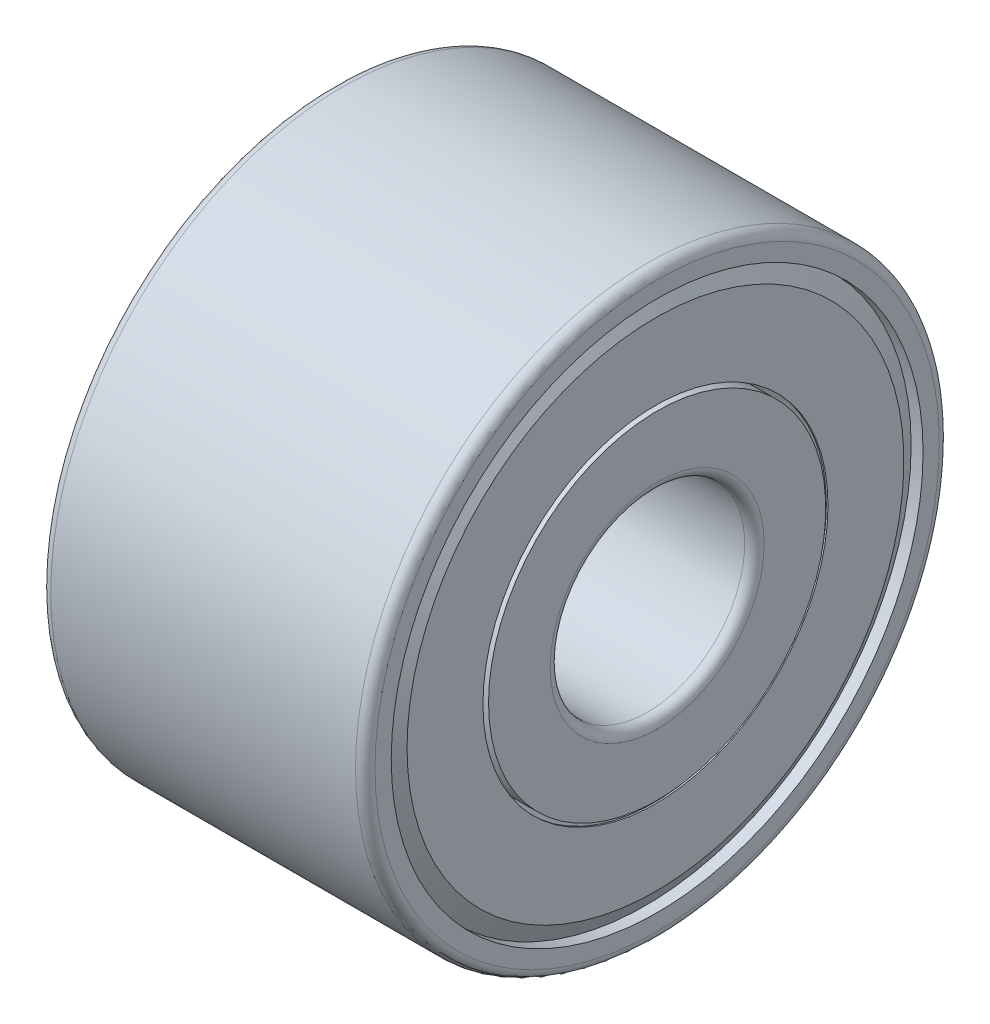
from build123d import *


with BuildPart() as part:
    # Esquisse1 → Révolution1 (revolve)
    with BuildSketch(Plane(origin=(0, 0, 0), x_dir=(-1, 0, 0), z_dir=(0, 0, -1))):
        with BuildLine():
            Line((-4, 2.6), (-4, 1.65))
            ThreePointArc((-4, 1.65), (-3.956066017, 1.543933983), (-3.85, 1.5))
            Line((-3.85, 1.5), (0.85, 1.5))
            ThreePointArc((0.85, 1.5), (0.956066017, 1.543933983), (1, 1.65))
            Line((1, 1.65), (1, 2.6))
            Line((1, 2.6), (0.112460986, 2.6))
            ThreePointArc((0.112460986, 2.6), (0.334185749, 3.208515617), (0.245017849, 3.85))
            Line((0.245017849, 3.85), (0.636363636, 3.85))
            Line((0.636363636, 3.85), (0.636363636, 4.1))
            ThreePointArc((0.636363636, 4.1), (0.668034506, 4.168958654), (0.740980147, 4.189869736))
            Line((0.740980147, 4.189869736), (0.738174682, 4.18825))
            Line((0.738174682, 4.18825), (0.949, 3.823089838))
            Line((0.949, 3.823089838), (0.949, 2.66))
            Line((0.949, 2.66), (0.974, 2.66))
            Line((0.974, 2.66), (0.974, 3.829788568))
            Line((0.974, 3.829788568), (0.815815707, 4.1))
            Line((0.815815707, 4.1), (1, 4.1))
            Line((1, 4.1), (1, 4.35))
            ThreePointArc((1, 4.35), (0.956066017, 4.456066017), (0.85, 4.5))
            Line((0.85, 4.5), (-3.85, 4.5))
            ThreePointArc((-3.85, 4.5), (-3.956066017, 4.456066017), (-4, 4.35))
            Line((-4, 4.35), (-4, 4.1))
            Line((-4, 4.1), (-3.815815707, 4.1))
            Line((-3.815815707, 4.1), (-3.974, 3.829788568))
            Line((-3.974, 3.829788568), (-3.974, 2.66))
            Line((-3.974, 2.66), (-3.949, 2.66))
            Line((-3.949, 2.66), (-3.949, 3.823089838))
            Line((-3.949, 3.823089838), (-3.738174682, 4.18825))
            Line((-3.738174682, 4.18825), (-3.740980147, 4.189869736))
            ThreePointArc((-3.740980147, 4.189869736), (-3.668034506, 4.168958654), (-3.636363636, 4.1))
            Line((-3.636363636, 4.1), (-3.636363636, 3.85))
            Line((-3.636363636, 3.85), (-3.245017849, 3.85))
            ThreePointArc((-3.245017849, 3.85), (-3.334185749, 3.208515617), (-3.112460986, 2.6))
            Line((-3.112460986, 2.6), (-4, 2.6))
        make_face()
    revolve(axis=Axis((4, 0, 0), (-1, 0, 0)))


solid = part.part
